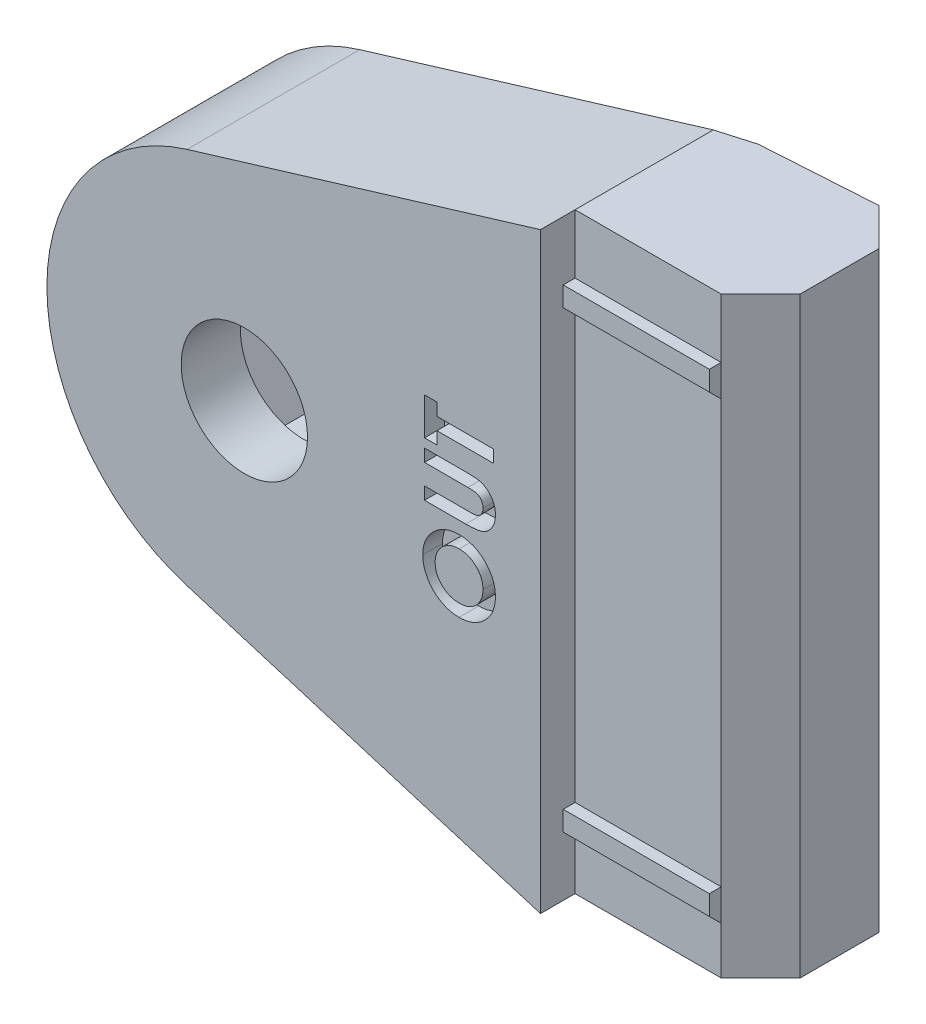
from build123d import *

# Parameters (mm, degrees)
SALIENTE_EXTRUIR1_DEPTH = 15
CROQUIS2_R              = 3.2
CORTAR_EXTRUIR1_DEPTH   = 10.75
CORTAR_EXTRUIR2_START   = -3
CORTAR_EXTRUIR2_DEPTH   = 5
CHAFL_N1_SIZE           = 2
SALIENTE_EXTRUIR3_DEPTH = 7.4
CROQUIS7_OUTSIDE_W      = 51.494
CROQUIS7_OUTSIDE_H      = 42.094
CORTAR_EXTRUIR3_DEPTH   = 10
CORTAR_EXTRUIR4_DEPTH   = 1
CHAFL_N2_SIZE           = 1
CORTAR_EXTRUIR5_DEPTH   = 31.0000001


with BuildPart() as part:
    # Croquis1 → Saliente-Extruir1 (new body, symmetric)
    with BuildSketch(Plane(origin=(0, 0, 0), x_dir=(1, 0, 0), z_dir=(0, 1, 0))):
        Polygon((0, 0), (-30, 0), (-30, 8), (-30, 9.75), (0, 9.75), (9.4, 9.75), (9.4, 1.75), (0, 1.75), align=None)
    extrude(amount=SALIENTE_EXTRUIR1_DEPTH, both=True)

    # Croquis2 → Cortar-Extruir1 (cut, through all)
    with BuildSketch(Plane.XY):
        with Locations((-15, 0)):
            Circle(CROQUIS2_R)
    extrude(amount=-CORTAR_EXTRUIR1_DEPTH, mode=Mode.SUBTRACT)

    # Croquis3 → Cortar-Extruir2 (cut)
    with BuildSketch(Plane.XY.offset(CORTAR_EXTRUIR2_START)):
        Polygon((-9.226497308, 0), (-12.113248654, 5), (-17.886751346, 5), (-20.773502692, 0), (-17.886751346, -5), (-12.113248654, -5), align=None)
    extrude(amount=-CORTAR_EXTRUIR2_DEPTH, mode=Mode.SUBTRACT)

    # Chaflán1
    chafl_n1_edges = [part.edges().sort_by_distance(p)[0] for p in [
        (9.4, 0, -9.75),
        (9.4, 0, -1.75),
        (-30, 15, -4.875),
        (-30, -15, -4.875),
    ]]
    chamfer(chafl_n1_edges, length=CHAFL_N1_SIZE)

    # Croquis5 → Saliente-Extruir3 (add)
    with BuildSketch(Plane(origin=(0, 0, 0), x_dir=(0, 0, -1), z_dir=(1, 0, 0))):
        Polygon((1.75, 12), (1.15, 12), (1.15, 11), (1.75, 10.4), align=None)
        Polygon((1.75, -11), (1.15, -11), (1.15, -12), (1.75, -12.6), align=None)
    extrude(amount=SALIENTE_EXTRUIR3_DEPTH)

    # Croquis7 outside → Cortar-Extruir3 (cut)
    with BuildSketch(Plane.XY):
        with Locations((-10.3, 0)):
            Rectangle(CROQUIS7_OUTSIDE_W, CROQUIS7_OUTSIDE_H)
        with BuildLine():
            Line((-17.902762311, 9.569428978), (0, 15))
            Line((0, 15), (9.4, 15))
            Line((9.4, 15), (9.4, -15))
            Line((9.4, -15), (0, -15))
            Line((0, -15), (-17.902762311, -9.569428978))
            ThreePointArc((-17.902762311, -9.569428978), (-25, 0), (-17.902762311, 9.569428978))
        make_face(mode=Mode.SUBTRACT)
    extrude(amount=-CORTAR_EXTRUIR3_DEPTH, mode=Mode.SUBTRACT)

    # Croquis8 → Cortar-Extruir4 (cut)
    with BuildSketch(Plane.XY):
        with BuildLine():
            add(Edge.make_bspline(
                [(-5.963745604, -2.244736554), (-5.962169735, -2.183884953), (-5.959058614, -2.06375011), (-5.933134456, -1.887071843), (-5.890871203, -1.716822341), (-5.832205589, -1.553018478), (-5.75523655, -1.396404454), (-5.663493409, -1.245453867), (-5.552988397, -1.102078592), (-5.42765723, -0.966773962), (-5.291276331, -0.84176777), (-5.144443111, -0.733477469), (-4.99084204, -0.640878388), (-4.829891005, -0.564698347), (-4.661041265, -0.506181737), (-4.484996426, -0.465297844), (-4.30170881, -0.438998427), (-4.176911088, -0.43597611), (-4.113485187, -0.434440079)],
                knots=[0, 0, 0, 0, 0.000182486, 0.000360268, 0.000534396, 0.00070805, 0.00088114, 0.00105706, 0.001237116, 0.001423178, 0.0016098, 0.001791254, 0.001969572, 0.002147089, 0.002324474, 0.002504569, 0.0026886, 0.00287879, 0.00287879, 0.00287879, 0.00287879], degree=3))
            add(Edge.make_bspline(
                [(-4.113485187, -0.434440079), (-4.050774145, -0.436076417), (-3.927200024, -0.439300873), (-3.745598675, -0.4642191), (-3.571449927, -0.505817623), (-3.404399806, -0.563182423), (-3.245290662, -0.638113892), (-3.093458349, -0.729128686), (-2.949423595, -0.837185581), (-2.813793322, -0.959695525), (-2.689842624, -1.093733293), (-2.581324784, -1.23649467), (-2.489392234, -1.38627829), (-2.413686479, -1.542966843), (-2.356577624, -1.707689432), (-2.313872415, -1.878586676), (-2.289168642, -2.057048545), (-2.285911624, -2.178289242), (-2.284258424, -2.239828701)],
                knots=[0, 0, 0, 0, 0.000188089, 0.000370635, 0.000548684, 0.000724515, 0.000899532, 0.001075324, 0.001254672, 0.001438843, 0.001622923, 0.001801572, 0.00197593, 0.002149347, 0.002322529, 0.002498019, 0.002677092, 0.002861679, 0.002861679, 0.002861679, 0.002861679], degree=3))
            add(Edge.make_bspline(
                [(-2.284258424, -2.239828701), (-2.285724224, -2.304196447), (-2.288604319, -2.430670268), (-2.315761668, -2.615811218), (-2.357166663, -2.79293944), (-2.417111133, -2.961569597), (-2.495000626, -3.1215706), (-2.589046245, -3.273659984), (-2.70106461, -3.416693903), (-2.827677057, -3.550195582), (-2.966254773, -3.671134337), (-3.112640517, -3.777890194), (-3.26572726, -3.867940202), (-3.425583727, -3.941288989), (-3.59121721, -3.999114165), (-3.763636264, -4.039903271), (-3.94242742, -4.063998366), (-4.063865945, -4.067354674), (-4.125404258, -4.069055464)],
                knots=[0, 0, 0, 0, 0.000192992, 0.000379203, 0.000560143, 0.000737993, 0.000914849, 0.001093067, 0.001273424, 0.001458907, 0.001644244, 0.001824454, 0.002001698, 0.002176124, 0.002351292, 0.002527132, 0.002706806, 0.002891392, 0.002891392, 0.002891392, 0.002891392], degree=3))
            add(Edge.make_bspline(
                [(-4.125404258, -4.069055464), (-4.166803953, -4.068521502), (-4.24907913, -4.067460339), (-4.371007795, -4.054683543), (-4.490552451, -4.036276798), (-4.607255893, -4.009098138), (-4.72207958, -3.975867179), (-4.83400056, -3.933375701), (-4.943777834, -3.884385809), (-5.050181022, -3.827744186), (-5.151984521, -3.763710588), (-5.250063521, -3.695329281), (-5.34185123, -3.619996502), (-5.428326615, -3.539251814), (-5.509158433, -3.452825317), (-5.58426266, -3.360542781), (-5.654498853, -3.26306705), (-5.718934596, -3.16038916), (-5.775892027, -3.05326856), (-5.826897705, -2.944069051), (-5.868768832, -2.832336844), (-5.903242792, -2.718726738), (-5.930946802, -2.603399298), (-5.94935888, -2.485437881), (-5.962130593, -2.365845077), (-5.963205989, -2.285201867), (-5.963745604, -2.244736554)],
                knots=[0, 0, 0, 0, 0.000124148, 0.000246724, 0.000367409, 0.000486805, 0.000605941, 0.000725748, 0.00084563, 0.000966388, 0.001087007, 0.001206249, 0.001324841, 0.0014429, 0.001560959, 0.001679551, 0.001799606, 0.001921192, 0.002042899, 0.002163361, 0.002282513, 0.002400505, 0.002519378, 0.002637986, 0.002758469, 0.002879813, 0.002879813, 0.002879813, 0.002879813], degree=3))
        make_face()
        with BuildLine():
            add(Edge.make_bspline(
                [(-5.335540475, -2.254552259), (-5.334441608, -2.295505505), (-5.332272883, -2.376330825), (-5.315750133, -2.49488685), (-5.289361424, -2.608704821), (-5.251137701, -2.7171538), (-5.202488602, -2.820703813), (-5.143584114, -2.919538424), (-5.072399461, -3.012288978), (-4.992756229, -3.100192212), (-4.904015366, -3.179598319), (-4.808914439, -3.24975612), (-4.707612265, -3.308466899), (-4.601049918, -3.357637545), (-4.488029132, -3.394652143), (-4.369435211, -3.421016532), (-4.245063812, -3.437677841), (-4.160279991, -3.43977802), (-4.116990796, -3.440850336)],
                knots=[0, 0, 0, 0, 0.000122824, 0.000242406, 0.000358388, 0.000472807, 0.000586661, 0.000701131, 0.000817238, 0.000936842, 0.001056496, 0.001173871, 0.001290754, 0.001407153, 0.001525327, 0.001646775, 0.001771221, 0.00190105, 0.00190105, 0.00190105, 0.00190105], degree=3))
            add(Edge.make_bspline(
                [(-4.116990796, -3.440850336), (-4.069018016, -3.439425346), (-3.974999315, -3.436632603), (-3.837823916, -3.417073374), (-3.708152988, -3.383311134), (-3.586630375, -3.335431854), (-3.472571656, -3.274749559), (-3.36661958, -3.200422254), (-3.268275884, -3.112461947), (-3.210843666, -3.04473561), (-3.181694322, -3.010361554)],
                knots=[0, 0, 0, 0, 0.000143901, 0.000282022, 0.000414667, 0.000544995, 0.00067297, 0.000801345, 0.000932411, 0.001067493, 0.001067493, 0.001067493, 0.001067493], degree=3))
            add(Edge.make_bspline(
                [(-3.181694322, -3.010361554), (-3.160160982, -2.982200275), (-3.117579453, -2.926512197), (-3.063002488, -2.837621899), (-3.016224585, -2.746082395), (-2.978428592, -2.651202906), (-2.9486989, -2.553183811), (-2.927879685, -2.452038553), (-2.914813827, -2.347910444), (-2.91325221, -2.277494138), (-2.912463552, -2.241932067)],
                knots=[0, 0, 0, 0, 0.000106293, 0.000210192, 0.000312412, 0.000414354, 0.000516162, 0.000619291, 0.000723822, 0.000830475, 0.000830475, 0.000830475, 0.000830475], degree=3))
            add(Edge.make_bspline(
                [(-2.912463552, -2.241932067), (-2.913573368, -2.201683837), (-2.915756965, -2.122494178), (-2.932053021, -2.006133368), (-2.959756921, -1.894710751), (-2.99736261, -1.787179969), (-3.047817383, -1.685031451), (-3.107424712, -1.586640203), (-3.179071565, -1.493721491), (-3.260392949, -1.406309236), (-3.349445656, -1.326131952), (-3.444577822, -1.255400445), (-3.544904266, -1.19572387), (-3.650408392, -1.146928169), (-3.760974251, -1.108704995), (-3.876940544, -1.082607371), (-3.997778921, -1.065819054), (-4.080008036, -1.063716386), (-4.121898649, -1.062645208)],
                knots=[0, 0, 0, 0, 0.000120723, 0.000237527, 0.000351629, 0.000464725, 0.000578551, 0.000692784, 0.000809316, 0.00092987, 0.001050514, 0.001168305, 0.00128494, 0.001400065, 0.00151647, 0.001635184, 0.001756155, 0.001881781, 0.001881781, 0.001881781, 0.001881781], degree=3))
            add(Edge.make_bspline(
                [(-4.121898649, -1.062645208), (-4.163549902, -1.063749641), (-4.245534042, -1.065923551), (-4.366039975, -1.082311752), (-4.48135889, -1.109556579), (-4.591788052, -1.148062226), (-4.697907204, -1.196032251), (-4.798795324, -1.256290588), (-4.894365125, -1.327531108), (-4.984048433, -1.408451474), (-5.066467173, -1.496513831), (-5.137990249, -1.591061389), (-5.200141894, -1.689444079), (-5.248828896, -1.793920463), (-5.28761775, -1.902352735), (-5.316182412, -2.015402636), (-5.33215681, -2.133498327), (-5.334402533, -2.213841269), (-5.335540475, -2.254552259)],
                knots=[0, 0, 0, 0, 0.000124926, 0.000245897, 0.000364088, 0.00047983, 0.000596229, 0.000712864, 0.000831635, 0.000953269, 0.001074815, 0.001192886, 0.001308453, 0.00142324, 0.001537892, 0.001653524, 0.001772411, 0.001894535, 0.001894535, 0.001894535, 0.001894535], degree=3))
        make_face(mode=Mode.SUBTRACT)
        with BuildLine():
            Line((-5.874002014, 0.193765049), (-5.874002014, 0.821970177))
            Line((-5.874002014, 0.821970177), (-3.596758424, 0.821970177))
            add(Edge.make_bspline(
                [(-3.596758424, 0.821970177), (-3.573149113, 0.822005725), (-3.527547973, 0.822074385), (-3.462122649, 0.825358758), (-3.401760065, 0.828454239), (-3.346949509, 0.833721101), (-3.297520838, 0.841982545), (-3.253291943, 0.849695766), (-3.214656983, 0.860270735), (-3.17065019, 0.876106798), (-3.121213276, 0.900830472), (-3.06910474, 0.940044403), (-3.022723744, 0.986872478), (-2.983780096, 1.042019694), (-2.95084111, 1.103589645), (-2.929054729, 1.1727957), (-2.914277419, 1.247388072), (-2.913079482, 1.299356632), (-2.912463552, 1.326076748)],
                knots=[0, 0, 0, 0, 7.0817e-05, 0.000136782, 0.00019648, 0.000252152, 0.000301833, 0.000346798, 0.000386768, 0.00042181, 0.000487029, 0.000551673, 0.000616621, 0.000683943, 0.000753563, 0.000825177, 0.000900807, 0.000980846, 0.000980846, 0.000980846, 0.000980846], degree=3))
            add(Edge.make_bspline(
                [(-2.912463552, 1.326076748), (-2.913291002, 1.354432785), (-2.914904389, 1.409722258), (-2.930741527, 1.489247362), (-2.955959675, 1.562927821), (-2.991952397, 1.629203576), (-3.035095987, 1.688008639), (-3.084293187, 1.737785981), (-3.139642172, 1.77706977), (-3.190705703, 1.80267444), (-3.237705542, 1.817047925), (-3.279697058, 1.827830164), (-3.329018659, 1.83565942), (-3.385327782, 1.842989217), (-3.449034699, 1.847144768), (-3.519806391, 1.851877302), (-3.597685918, 1.853574428), (-3.651913768, 1.853868244), (-3.680191918, 1.854021459)],
                knots=[0, 0, 0, 0, 8.4978e-05, 0.000165692, 0.000242191, 0.000317789, 0.000390988, 0.000460396, 0.00052674, 0.000593843, 0.00063065, 0.000674012, 0.000723806, 0.000780333, 0.000844323, 0.000915261, 0.000993114, 0.001077953, 0.001077953, 0.001077953, 0.001077953], degree=3))
            Line((-3.680191918, 1.854021459), (-5.874002014, 1.854021459))
            Line((-5.874002014, 1.854021459), (-5.874002014, 2.482226587))
            Line((-5.874002014, 2.482226587), (-3.786061309, 2.482226587))
            add(Edge.make_bspline(
                [(-3.786061309, 2.482226587), (-3.74375973, 2.48213935), (-3.662417919, 2.4819716), (-3.545524013, 2.479395472), (-3.43876018, 2.473911362), (-3.342095225, 2.469305342), (-3.255659372, 2.460391114), (-3.17908351, 2.451104584), (-3.112639023, 2.439268092), (-3.037000001, 2.42165614), (-2.94990475, 2.391262902), (-2.849616878, 2.342266067), (-2.751434696, 2.280063765), (-2.656409874, 2.20655927), (-2.568219841, 2.123507582), (-2.490580212, 2.033111155), (-2.425978758, 1.935784665), (-2.373745522, 1.831977669), (-2.333526246, 1.720594748), (-2.305098237, 1.601373203), (-2.287008707, 1.473631248), (-2.285193561, 1.385502077), (-2.284258424, 1.340099183)],
                knots=[0, 0, 0, 0, 0.000126905, 0.000244026, 0.000350709, 0.000447627, 0.000534274, 0.000611324, 0.000678989, 0.000736639, 0.000844176, 0.000954866, 0.001070804, 0.001192252, 0.001314756, 0.001433618, 0.001548931, 0.001664318, 0.001781424, 0.001903351, 0.002031459, 0.002167592, 0.002167592, 0.002167592, 0.002167592], degree=3))
            add(Edge.make_bspline(
                [(-2.284258424, 1.340099183), (-2.284768066, 1.309929111), (-2.285773578, 1.250404177), (-2.294593269, 1.162854752), (-2.307697061, 1.078250004), (-2.326443426, 0.996545055), (-2.352033522, 0.918021639), (-2.382274777, 0.84217153), (-2.416876512, 0.768719968), (-2.458869672, 0.699962412), (-2.502978655, 0.634209727), (-2.551240699, 0.573667793), (-2.601515595, 0.51740575), (-2.654954103, 0.466077088), (-2.711175551, 0.419633834), (-2.770234972, 0.37811208), (-2.832146131, 0.341589349), (-2.898019812, 0.309141924), (-2.971205998, 0.28137299), (-3.05430542, 0.257950997), (-3.148404174, 0.237589741), (-3.254122164, 0.22217619), (-3.37097804, 0.208591064), (-3.499417751, 0.19978846), (-3.639025703, 0.195244792), (-3.735811, 0.19427076), (-3.786061309, 0.193765049)],
                knots=[0, 0, 0, 0, 9.0488e-05, 0.000178531, 0.000263714, 0.000347218, 0.000429701, 0.000511203, 0.000592109, 0.000672911, 0.000752642, 0.00082951, 0.000904971, 0.000978856, 0.00105157, 0.00112354, 0.001195205, 0.001267011, 0.001343575, 0.001429673, 0.001525798, 0.001632196, 0.001750039, 0.001878667, 0.002018277, 0.002169033, 0.002169033, 0.002169033, 0.002169033], degree=3))
            Line((-3.786061309, 0.193765049), (-5.874002014, 0.193765049))
        make_face()
        Polygon((-5.874002014, 2.930944536), (-5.874002014, 4.815559921), (-5.245796886, 4.815559921), (-5.245796886, 4.187354792), (-2.374002014, 4.187354792), (-2.374002014, 3.559149664), (-5.245796886, 3.559149664), (-5.245796886, 2.930944536), align=None)
    extrude(amount=-CORTAR_EXTRUIR4_DEPTH, mode=Mode.SUBTRACT)

    # Chaflán2
    chafl_n2_edges = [part.edges().sort_by_distance(p)[0] for p in [
        (-25, 0, -9.75),
        (-8.951381156, 12.284714489, -9.75),
        (-8.951381156, -12.284714489, -9.75),
    ]]
    chamfer(chafl_n2_edges, length=CHAFL_N2_SIZE)

    # Croquis9 → Cortar-Extruir5 (cut, through all)
    with BuildSketch(Plane(origin=(0, 15, 0), x_dir=(1, 0, 0), z_dir=(0, 1, 0))):
        Polygon((0, 9.15), (0, 9.75), (9.382446906, 9.75), align=None)
    extrude(amount=-CORTAR_EXTRUIR5_DEPTH, mode=Mode.SUBTRACT)


solid = part.part
